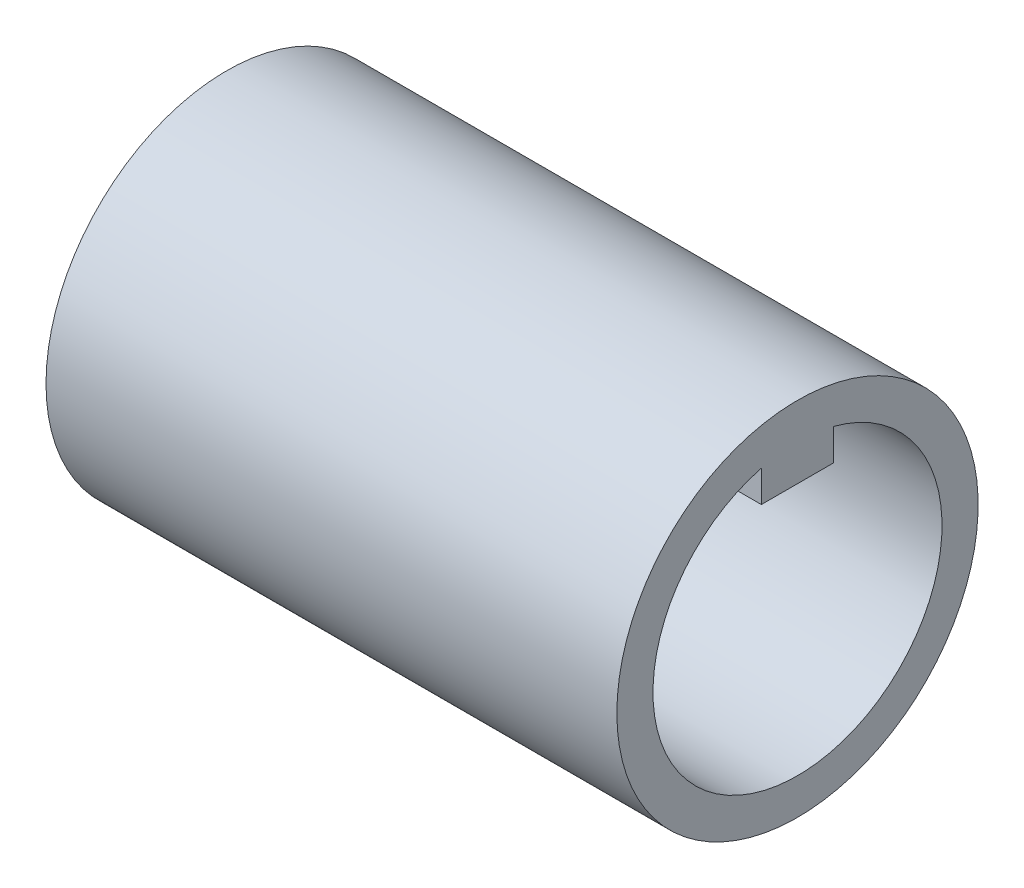
from build123d import *

# Parameters (mm, degrees)
SKETCH_2_W      = 5
SKETCH_2_H      = 2.5
EXTRUDE_1_DEPTH = 39.5


with BuildPart() as part:
    # Эскиз1 → Повернуть1 (revolve)
    with BuildSketch(Plane(origin=(0, 0, 0), x_dir=(1, 0, 0), z_dir=(0, 1, 0))):
        Polygon((0, 10), (-35.5, 10), (-35.5, 4.25), (-39.5, 4.25), (-39.5, 12.5), (0, 12.5), align=None)
    revolve(axis=Axis((-1000, 0, 0), (1, 0, 0)))

    # Эскиз2 → Бобышка-Вытянуть1 (add)
    with BuildSketch(Plane.ZY.offset(39.5)):
        with Locations((0, 8.75)):
            Rectangle(SKETCH_2_W, SKETCH_2_H)
    extrude(amount=-EXTRUDE_1_DEPTH)


solid = part.part
